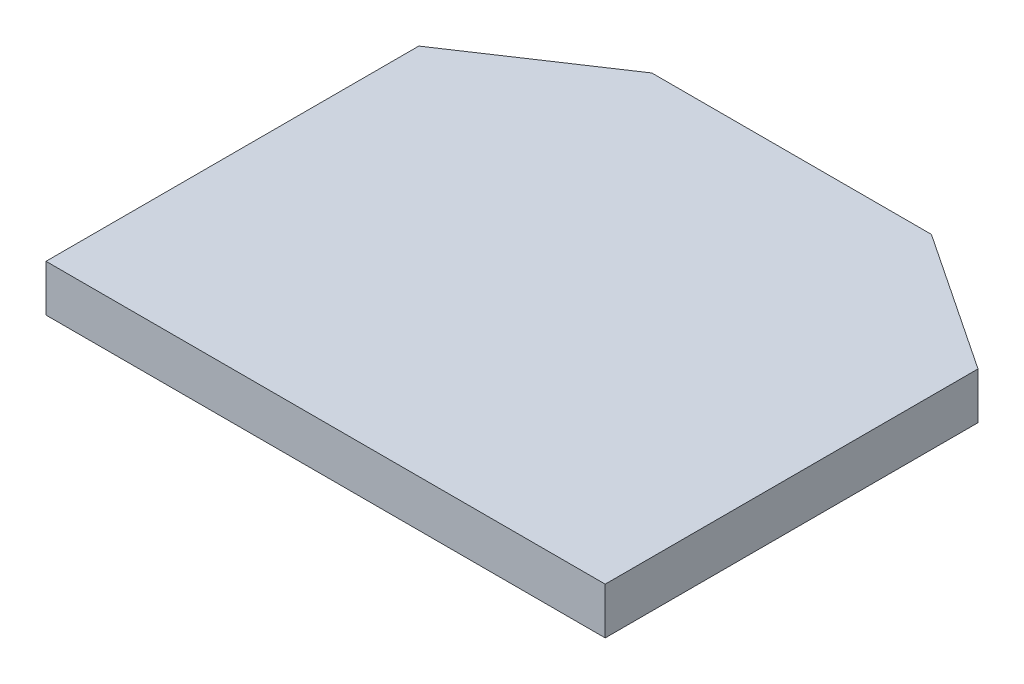
from build123d import *

# Parameters (mm, degrees)
BOSS_EXTRUDE1_DEPTH = 6.35


with BuildPart() as part:
    # Sketch2 → Boss-Extrude1 (new body)
    with BuildSketch(Plane(origin=(0, 0, 0), x_dir=(1, 0, 0), z_dir=(0, 1, 0))):
        Polygon((-38.1, 0), (38.1, 0), (38.1, 50.8), (19.05, 63.5), (-19.05, 63.5), (-38.1, 50.8), align=None)
    extrude(amount=BOSS_EXTRUDE1_DEPTH)


solid = part.part
